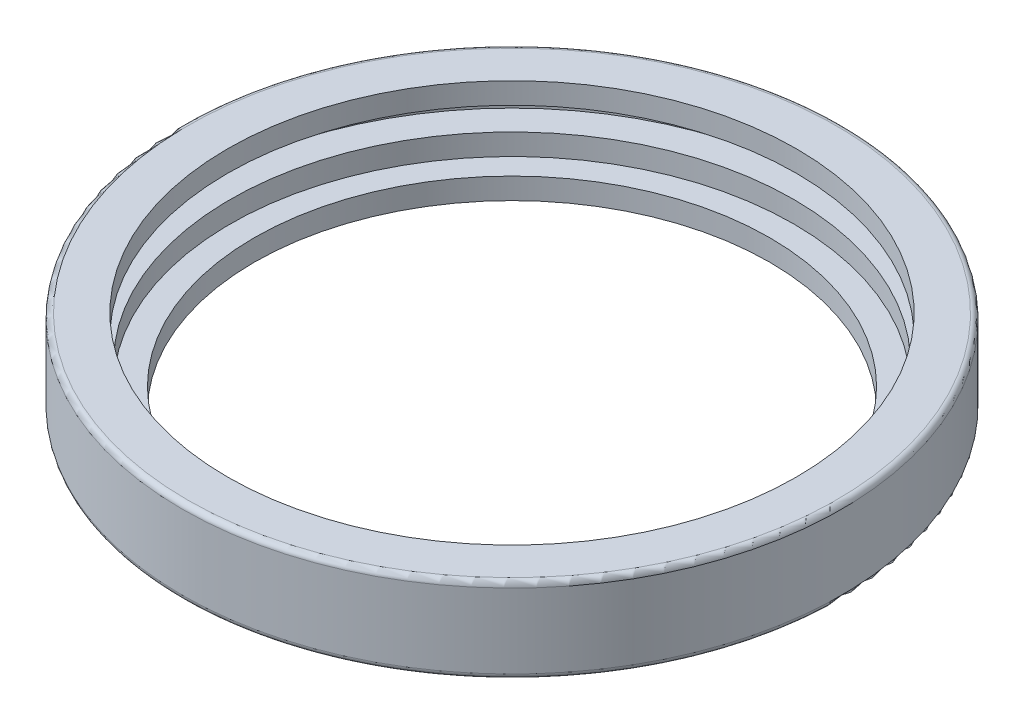
from build123d import *

# Parameters (mm, degrees)
FILLET1_R = 0.5


with BuildPart() as part:
    # Sketch1 → Revolve1 (revolve)
    with BuildSketch(Plane.XY):
        Polygon((24.25, 0), (31, 0), (31, 8), (26.75, 8), (26.75, 6), (29.25, 6), (29.25, 4), (26.5, 4), (26.5, 2), (24.25, 2), align=None)
    revolve(axis=Axis((0, 0, 0), (0, 1, 0)))

    # Fillet1
    fillet1_edges = [part.edges().sort_by_distance(p)[0] for p in [
        (-31, 8, 0),
        (-31, 0, 0),
    ]]
    fillet(fillet1_edges, radius=FILLET1_R)


solid = part.part
